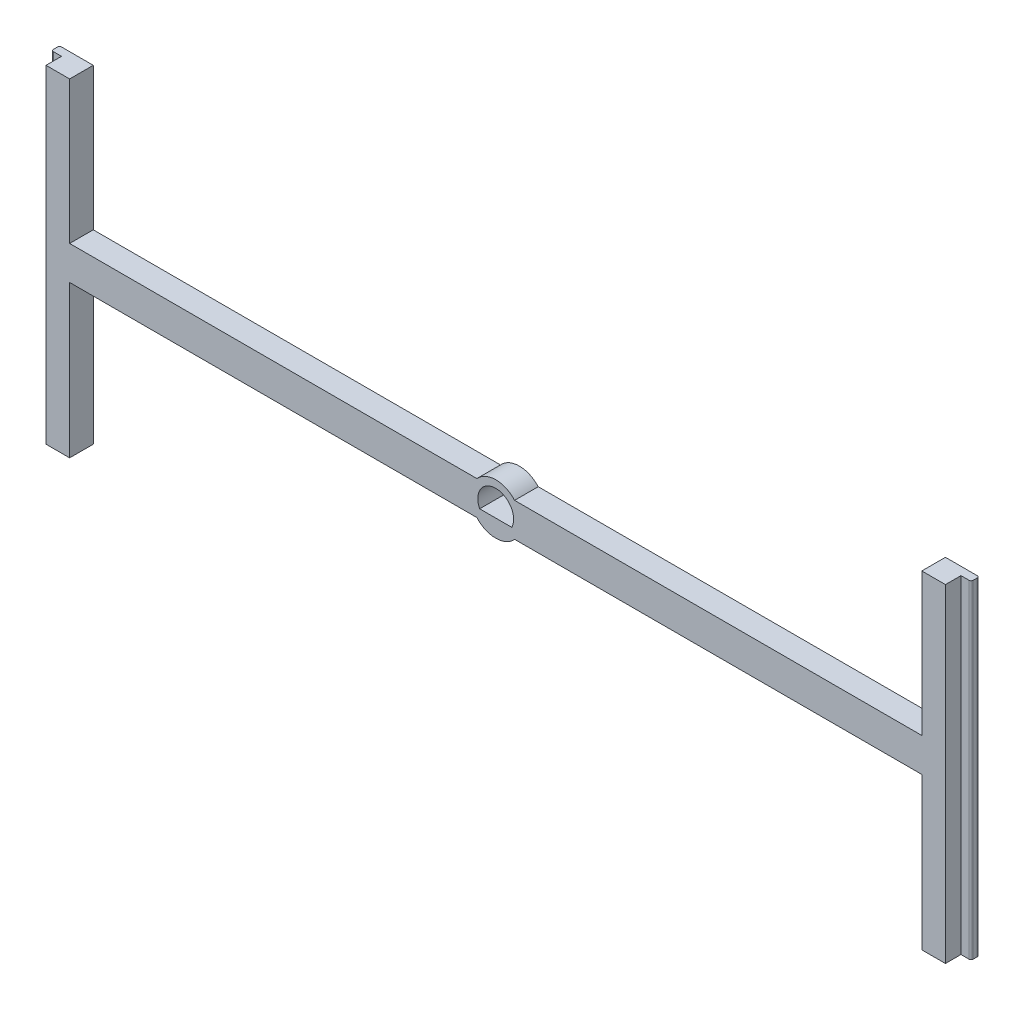
from build123d import *

# Parameters (mm, degrees)
BOSS_EXTRUDE1_DEPTH = 3.5
SKETCH2_W           = 1.5
SKETCH2_H           = 2.3
CUT_EXTRUDE1_DEPTH  = 51
SKETCH3_W           = 136.2
SKETCH3_H           = 1.4
CUT_EXTRUDE2_DEPTH  = 4.5
FILLET1_R           = 0.3


with BuildPart() as part:
    # Sketch1 → Boss-Extrude1 (new body)
    with BuildSketch(Plane.XY):
        with BuildLine():
            Line((-63.1, 2.5), (-2.795084972, 2.5))
            ThreePointArc((-2.795084972, 2.5), (0, 3.75), (2.795084972, 2.5))
            Line((2.795084972, 2.5), (63.1, 2.5))
            Line((63.1, 2.5), (63.1, 25))
            Line((63.1, 25), (68.1, 25))
            Line((68.1, 25), (68.1, -25))
            Line((68.1, -25), (63.1, -25))
            Line((63.1, -25), (63.1, -2.5))
            Line((63.1, -2.5), (2.795084972, -2.5))
            ThreePointArc((2.795084972, -2.5), (0, -3.75), (-2.795084972, -2.5))
            Line((-2.795084972, -2.5), (-63.1, -2.5))
            Line((-63.1, -2.5), (-63.1, -25))
            Line((-63.1, -25), (-68.1, -25))
            Line((-68.1, -25), (-68.1, 25))
            Line((-68.1, 25), (-63.1, 25))
            Line((-63.1, 25), (-63.1, 2.5))
        make_face()
        with BuildLine():
            Line((-2.37773001, -1.17), (2.37773001, -1.17))
            ThreePointArc((2.37773001, -1.17), (0, 2.65), (-2.37773001, -1.17))
        make_face(mode=Mode.SUBTRACT)
    extrude(amount=BOSS_EXTRUDE1_DEPTH)

    # Sketch2 → Cut-Extrude1 (cut, through all)
    with BuildSketch(Plane.XZ.offset(25)):
        with Locations((67.35, 2.35)):
            Rectangle(SKETCH2_W, SKETCH2_H)
        with Locations((-67.35, 2.35)):
            Rectangle(SKETCH2_W, SKETCH2_H)
    extrude(amount=-CUT_EXTRUDE1_DEPTH, mode=Mode.SUBTRACT)

    # Sketch3 → Cut-Extrude2 (cut, through all)
    with BuildSketch(Plane.XY.offset(3.5)):
        with Locations((0, 24.3)):
            Rectangle(SKETCH3_W, SKETCH3_H)
    extrude(amount=-CUT_EXTRUDE2_DEPTH, mode=Mode.SUBTRACT)

    # Fillet1
    fillet1_edges = [part.edges().sort_by_distance(p)[0] for p in [
        (68.1, -0.7, 0),
        (-68.1, -0.7, 1.2),
        (68.1, -0.7, 1.2),
        (-68.1, -0.7, 0),
    ]]
    fillet(fillet1_edges, radius=FILLET1_R)


solid = part.part
